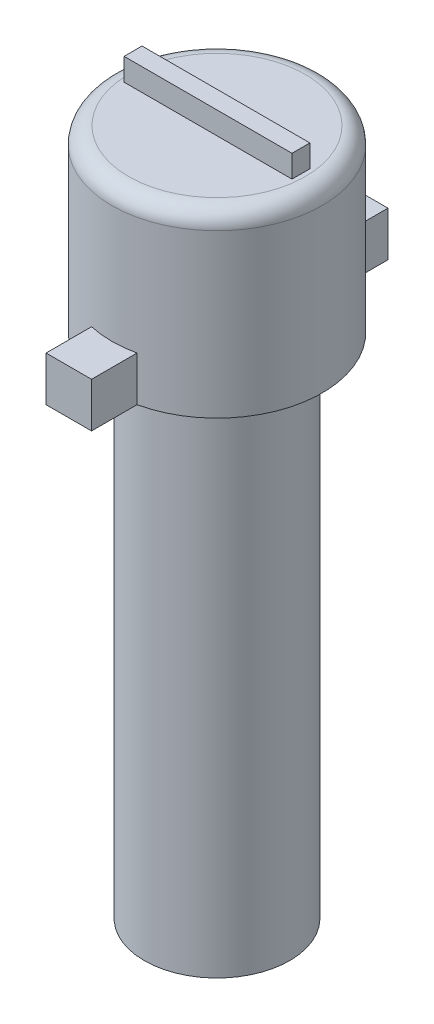
from build123d import *

# Parameters (mm, degrees)
SKETCH1_R           = 3.25
BOSS_EXTRUDE1_DEPTH = 22.686
SKETCH6_R           = 4.7
BOSS_EXTRUDE2_DEPTH = 8
BOSS_EXTRUDE3_DEPTH = 1
FILLET1_R           = 0.75
SKETCH9_W           = 0.8
SKETCH9_H           = 3.35
CUT_EXTRUDE3_DEPTH  = 1
BOSS_EXTRUDE4_DEPTH = 2


with BuildPart() as part:
    # Sketch1 → Boss-Extrude1 (new body)
    with BuildSketch(Plane(origin=(0, 0, 0), x_dir=(1, 0, 0), z_dir=(0, 1, 0))):
        Circle(SKETCH1_R)
    extrude(amount=BOSS_EXTRUDE1_DEPTH)

    # Sketch6 → Boss-Extrude2 (add)
    with BuildSketch(Plane(origin=(0, 22.686, 0), x_dir=(1, 0, 0), z_dir=(0, 1, 0))):
        Circle(SKETCH6_R)
    extrude(amount=BOSS_EXTRUDE2_DEPTH)

    # Sketch8 → Boss-Extrude3 (add)
    with BuildSketch(Plane(origin=(0, 30.686, 0), x_dir=(1, 0, 0), z_dir=(0, 1, 0))):
        Polygon((0.4, 3.75), (-0.4, 3.75), (-0.4, 0.4), (-3.75, 0.4), (-3.75, -0.4), (-0.4, -0.4), (-0.4, -3.75), (0.4, -3.75), (0.4, -0.4), (3.75, -0.4), (3.75, 0.4), (0.4, 0.4), align=None)
    extrude(amount=BOSS_EXTRUDE3_DEPTH)

    # Fillet1
    fillet1_edges = [part.edges().sort_by_distance(p)[0] for p in [
        (-4.7, 30.686, 0),
    ]]
    fillet(fillet1_edges, radius=FILLET1_R)

    # Sketch9 → Cut-Extrude3 (cut)
    with BuildSketch(Plane(origin=(0, 30.686, 0), x_dir=(1, 0, 0), z_dir=(0, 1, 0))):
        with Locations((0, 2.075)):
            Rectangle(SKETCH9_W, SKETCH9_H)
        with Locations((0, -2.075)):
            Rectangle(SKETCH9_W, SKETCH9_H)
    extrude(amount=CUT_EXTRUDE3_DEPTH, mode=Mode.SUBTRACT)

    # Sketch10 → Boss-Extrude4 (add)
    with BuildSketch(Plane.XZ.offset(-22.686)):
        with BuildLine():
            Line((-1.016, 6.620871757), (-1.016, 4.588871757))
            ThreePointArc((-1.016, 4.588871757), (0, 4.7), (1.016, 4.588871757))
            Line((1.016, 4.588871757), (1.016, 6.620871757))
            Line((1.016, 6.620871757), (-1.016, 6.620871757))
        make_face()
        with BuildLine():
            ThreePointArc((1.016, -4.588871757), (0, -4.7), (-1.016, -4.588871757))
            Line((-1.016, -4.588871757), (-1.016, -6.620871757))
            Line((-1.016, -6.620871757), (1.016, -6.620871757))
            Line((1.016, -6.620871757), (1.016, -4.588871757))
        make_face()
    extrude(amount=-BOSS_EXTRUDE4_DEPTH)


solid = part.part
